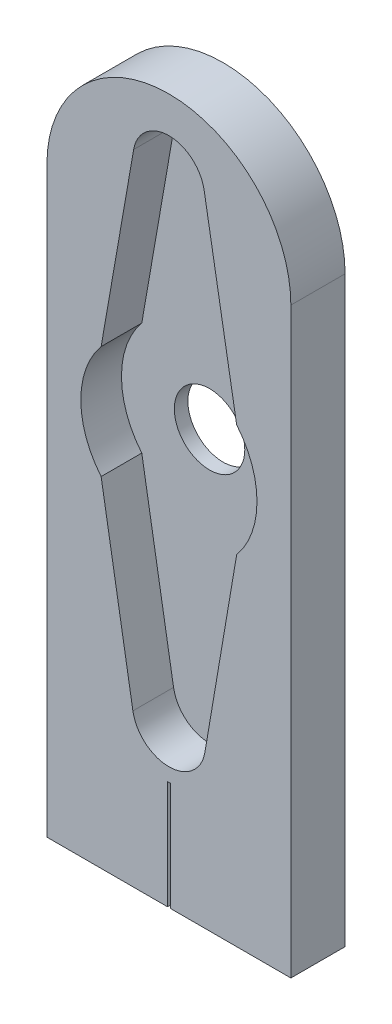
from build123d import *

# Parameters (mm, degrees)
EXTRUDE_1_DEPTH          = 4
CUT_EXTRUDE_1_DEPTH      = 3
SKETCH_4_R               = 2.6
CUT_EXTRUDE_9_DEPTH      = 19
CUT_EXTRUDE_9_DEPTH_BACK = 2
SKETCH_5_W               = 0.2
SKETCH_5_H               = 8
CUT_EXTRUDE_11_DEPTH     = 5


with BuildPart() as part:
    # 草圖1 → 填料-伸長1 (new body)
    with BuildSketch(Plane.XY):
        with BuildLine():
            Line((-9, 0), (-9, 43))
            ThreePointArc((-9, 43), (0, 52), (9, 43))
            Line((9, 43), (9, 0))
            Line((9, 0), (-9, 0))
        make_face()
    extrude(amount=EXTRUDE_1_DEPTH)

    # 草圖2 → 除料-伸長1 (cut)
    with BuildSketch(Plane.XY.offset(4)):
        with BuildLine():
            Line((-2.6, 47.145110573), (-5, 33.352358854))
            ThreePointArc((-5, 33.352358854), (-6.5, 29.199046922), (-5, 25.045734991))
            Line((-5, 25.045734991), (-2.656326538, 11.243300615))
            ThreePointArc((-2.656326538, 11.243300615), (0, 9), (2.656326538, 11.243300615))
            Line((2.656326538, 11.243300615), (5, 25.045734991))
            ThreePointArc((5, 25.045734991), (6.5, 29.199046922), (5, 33.352358854))
            Line((5, 33.352358854), (2.6, 47.145110573))
            ThreePointArc((2.6, 47.145110573), (0, 49.331766334), (-2.6, 47.145110573))
        make_face()
    extrude(amount=-CUT_EXTRUDE_1_DEPTH, mode=Mode.SUBTRACT)

    # 草圖4 → 除料-伸長9 (cut, two sides)
    with BuildSketch(Plane.XY) as cut_extrude_9_sk:
        with Locations((0, 29.065156497)):
            Circle(SKETCH_4_R)
    extrude(amount=CUT_EXTRUDE_9_DEPTH, mode=Mode.SUBTRACT)
    extrude(cut_extrude_9_sk.sketch, amount=-CUT_EXTRUDE_9_DEPTH_BACK, mode=Mode.SUBTRACT)

    # 草圖5 → 除料-伸長11 (cut, through all)
    with BuildSketch(Plane.XY):
        with Locations((0, 4)):
            Rectangle(SKETCH_5_W, SKETCH_5_H)
    extrude(amount=CUT_EXTRUDE_11_DEPTH, mode=Mode.SUBTRACT)


solid = part.part
